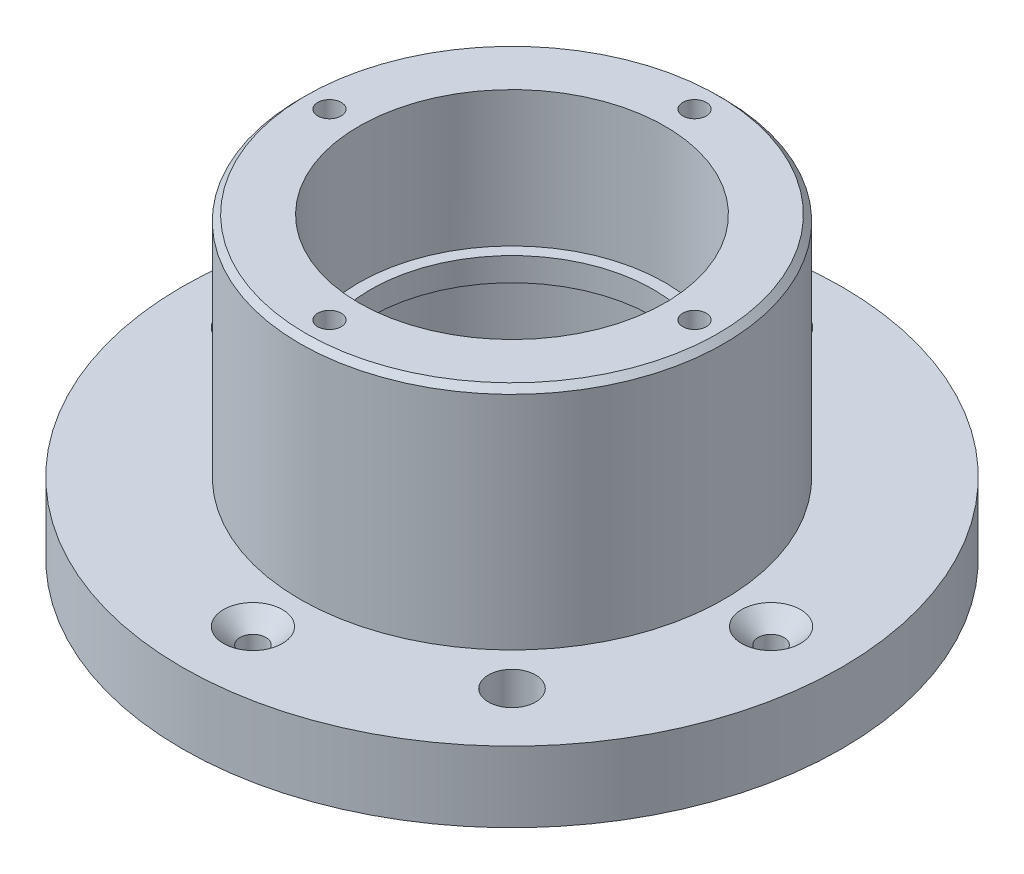
from build123d import *

# Parameters (mm, degrees)
SKETCH_1_R               = 26
EXTRUDE_1_DEPTH          = 4
SKETCH_2_R               = 18
EXTRUDE_2_DEPTH          = 19.3
SKETCH_3_R               = 13
CUT_EXTRUDE_1_DEPTH      = 10.3
SKETCH_6_R               = 13
CUT_EXTRUDE_4_DEPTH      = 14
SKETCH_7_R               = 1
CUT_EXTRUDE_5_DEPTH      = 5
SKETCH_8_R               = 28
SKETCH_8_R_2             = 26
EXTRUDE_3_DEPTH          = 6
CHAMFER_1_SIZE           = 0.5
CHAMFER_2_SIZE           = 0.5
PATTERN_CIRCULAR_1_COUNT = 4
SKETCH_10_R              = 15
CUT_EXTRUDE_7_DEPTH      = 11.8
SKETCH_11_R              = 15
SKETCH_11_R_2            = 12
EXTRUDE_4_DEPTH          = 2
SKETCH_12_R              = 2
CUT_EXTRUDE_8_DEPTH      = 10


with BuildPart() as part:
    # Эскиз1 → Бобышка-Вытянуть1 (new body)
    with BuildSketch(Plane(origin=(0, 0, 0), x_dir=(1, 0, 0), z_dir=(0, 1, 0))):
        Circle(SKETCH_1_R)
    extrude(amount=EXTRUDE_1_DEPTH)

    # Эскиз2 → Бобышка-Вытянуть2 (add)
    with BuildSketch(Plane(origin=(0, 4, 0), x_dir=(1, 0, 0), z_dir=(0, 1, 0))):
        Circle(SKETCH_2_R)
    extrude(amount=EXTRUDE_2_DEPTH)

    # Эскиз3 → Вырез-Вытянуть1 (cut)
    with BuildSketch(Plane(origin=(0, 23.3, 0), x_dir=(1, 0, 0), z_dir=(0, 1, 0))):
        Circle(SKETCH_3_R)
    extrude(amount=-CUT_EXTRUDE_1_DEPTH, mode=Mode.SUBTRACT)

    # Эскиз6 → Вырез-Вытянуть4 (cut, through all)
    with BuildSketch(Plane(origin=(0, 13, 0), x_dir=(1, 0, 0), z_dir=(0, 1, 0))):
        Circle(SKETCH_6_R)
    extrude(amount=-CUT_EXTRUDE_4_DEPTH, mode=Mode.SUBTRACT)

    # Эскиз7 → Вырез-Вытянуть5 (cut)
    with BuildSketch(Plane(origin=(0, 23.3, 0), x_dir=(1, 0, 0), z_dir=(0, 1, 0))):
        with Locations((-15.5, 0)):
            Circle(SKETCH_7_R)
        with Locations((0, 15.5)):
            Circle(SKETCH_7_R)
        with Locations((15.5, 0)):
            Circle(SKETCH_7_R)
        with Locations((0, -15.5)):
            Circle(SKETCH_7_R)
    extrude(amount=-CUT_EXTRUDE_5_DEPTH, mode=Mode.SUBTRACT)

    # Эскиз8 → Бобышка-Вытянуть3 (add)
    with BuildSketch(Plane(origin=(0, 4, 0), x_dir=(1, 0, 0), z_dir=(0, 1, 0))):
        Circle(SKETCH_8_R)
        Circle(SKETCH_8_R_2, mode=Mode.SUBTRACT)
    extrude(amount=-EXTRUDE_3_DEPTH)

    # Фаска1
    chamfer_1_edges = [part.edges().sort_by_distance(p)[0] for p in [
        (-26, -2, 0),
    ]]
    chamfer(chamfer_1_edges, length=CHAMFER_1_SIZE)

    # Фаска2
    chamfer_2_edges = [part.edges().sort_by_distance(p)[0] for p in [
        (-18, 23.3, 0),
    ]]
    chamfer(chamfer_2_edges, length=CHAMFER_2_SIZE)

    # Эскиз9 → Вырез-Повернуть2 (revolve, cut)
    with BuildSketch(Plane(origin=(0, 0, 0), x_dir=(0, 0, -1), z_dir=(1, 0, 0))):
        Polygon((-20.9, 2.648035715), (-19.5, 4), (-22, 4), (-22, 2.648035715), (-22, -2), (-20.9, -2), align=None)
    cut_revolve_2 = revolve(axis=Axis((0, -20.768821294, 22), (0, 1, 0)), mode=Mode.SUBTRACT)

    # Круговой массив1: Вырез-Повернуть2 ×4 about axis
    pattern_circular_1_axis = Axis((0, 0, 0), (0, 1, 0))
    for i in range(1, PATTERN_CIRCULAR_1_COUNT):
        add(cut_revolve_2.rotate(pattern_circular_1_axis, i * 360 / PATTERN_CIRCULAR_1_COUNT), mode=Mode.SUBTRACT)

    # Эскиз10 → Вырез-Вытянуть7 (cut)
    with BuildSketch(Plane.XZ):
        Circle(SKETCH_10_R)
    extrude(amount=-CUT_EXTRUDE_7_DEPTH, mode=Mode.SUBTRACT)

    # Эскиз11 → Бобышка-Вытянуть4 (add)
    with BuildSketch(Plane.XZ.offset(-11.8)):
        Circle(SKETCH_11_R)
        Circle(SKETCH_11_R_2, mode=Mode.SUBTRACT)
    extrude(amount=EXTRUDE_4_DEPTH)

    # Эскиз12 → Вырез-Вытянуть8 (cut)
    with BuildSketch(Plane(origin=(0, 4, 0), x_dir=(1, 0, 0), z_dir=(0, 1, 0))):
        with Locations((15.556349186, -15.556349186)):
            Circle(SKETCH_12_R)
    extrude(amount=-CUT_EXTRUDE_8_DEPTH, mode=Mode.SUBTRACT)


solid = part.part
